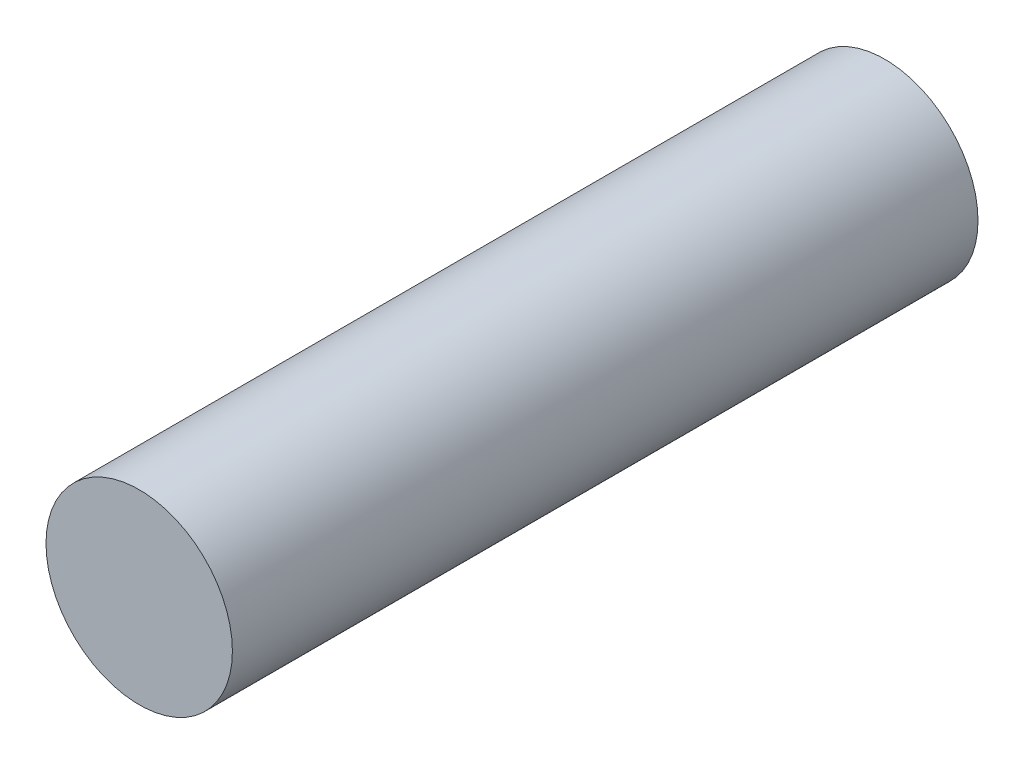
from build123d import *

# Parameters (mm, degrees)
SKETCH1_R          = 4.7625
BASE_EXTRUDE_DEPTH = 19.05


with BuildPart() as part:
    # Sketch1 → Base-Extrude (new body, symmetric)
    with BuildSketch(Plane.XY):
        Circle(SKETCH1_R)
    extrude(amount=BASE_EXTRUDE_DEPTH, both=True)


solid = part.part
